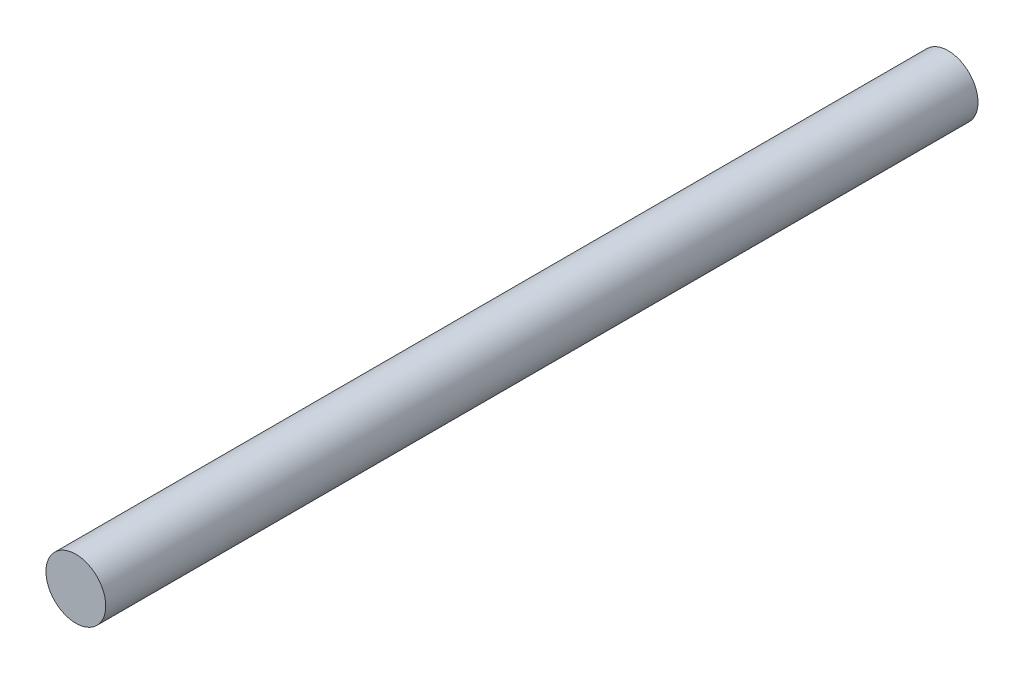
from build123d import *

# Parameters (mm, degrees)
SKETCH_1_R      = 6
EXTRUDE_1_DEPTH = 175


with BuildPart() as part:
    # 草圖1 → 填料-伸長1 (new body)
    with BuildSketch(Plane.XY):
        Circle(SKETCH_1_R)
    extrude(amount=EXTRUDE_1_DEPTH)


solid = part.part
